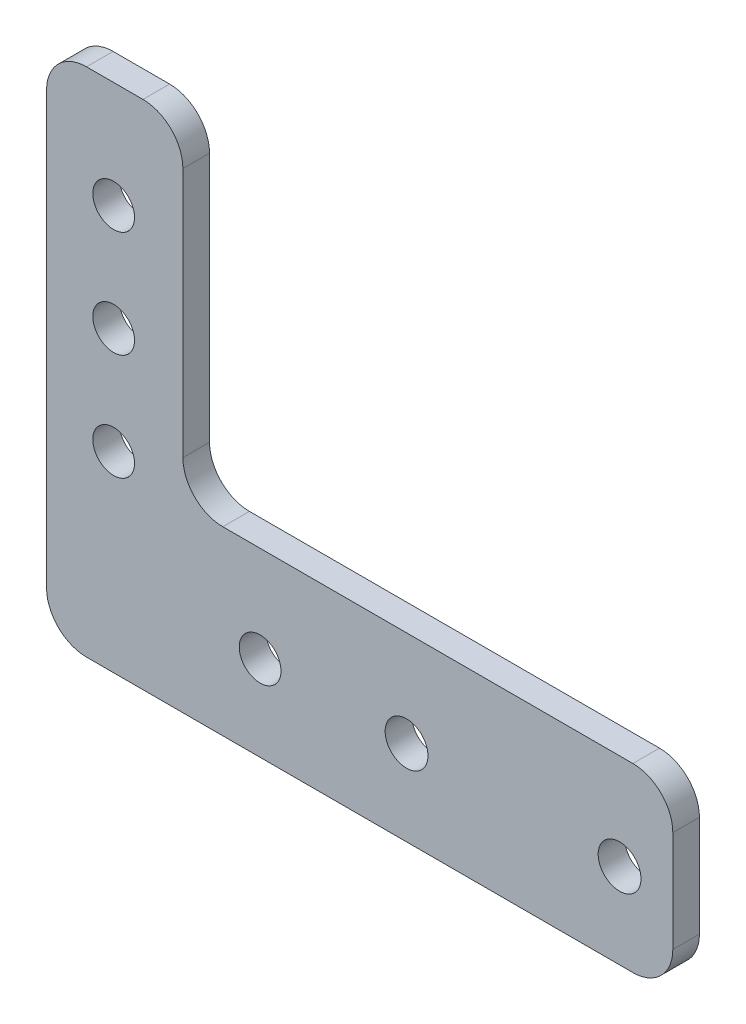
from build123d import *

# Parameters (mm, degrees)
SKETCH1_R           = 2.4892
SKETCH1_R_2         = 2.5527
BOSS_EXTRUDE1_DEPTH = 3.175
FILLET1_R           = 4.7625


with BuildPart() as part:
    # Sketch1 → Boss-Extrude1 (new body)
    with BuildSketch(Plane.XY):
        Polygon((-33.401, 31.75), (-33.401, -29.21), (41.275, -29.21), (41.275, -7.62), (-17.145, -7.62), (-17.145, 31.75), align=None)
        with Locations((-25.4, -19.05)):
            Circle(SKETCH1_R, mode=Mode.SUBTRACT)
        with Locations((-7.9375, -19.05)):
            Circle(SKETCH1_R, mode=Mode.SUBTRACT)
        with Locations((-25.4, -6.35)):
            Circle(SKETCH1_R, mode=Mode.SUBTRACT)
        with Locations((9.525, -19.05)):
            Circle(SKETCH1_R_2, mode=Mode.SUBTRACT)
        with Locations((34.925, -19.05)):
            Circle(SKETCH1_R_2, mode=Mode.SUBTRACT)
        with Locations((-25.4, 6.35)):
            Circle(SKETCH1_R, mode=Mode.SUBTRACT)
        with Locations((-25.4, 19.05)):
            Circle(SKETCH1_R, mode=Mode.SUBTRACT)
        with Locations((-25.4, -19.05)):
            Circle(SKETCH1_R)
    extrude(amount=BOSS_EXTRUDE1_DEPTH)

    # Fillet1
    fillet1_edges = [part.edges().sort_by_distance(p)[0] for p in [
        (-33.401, 31.75, 1.5875),
        (-17.145, 31.75, 1.5875),
        (-17.145, -7.62, 1.5875),
        (41.275, -7.62, 1.5875),
        (41.275, -29.21, 1.5875),
        (-33.401, -29.21, 1.5875),
    ]]
    fillet(fillet1_edges, radius=FILLET1_R)


solid = part.part
